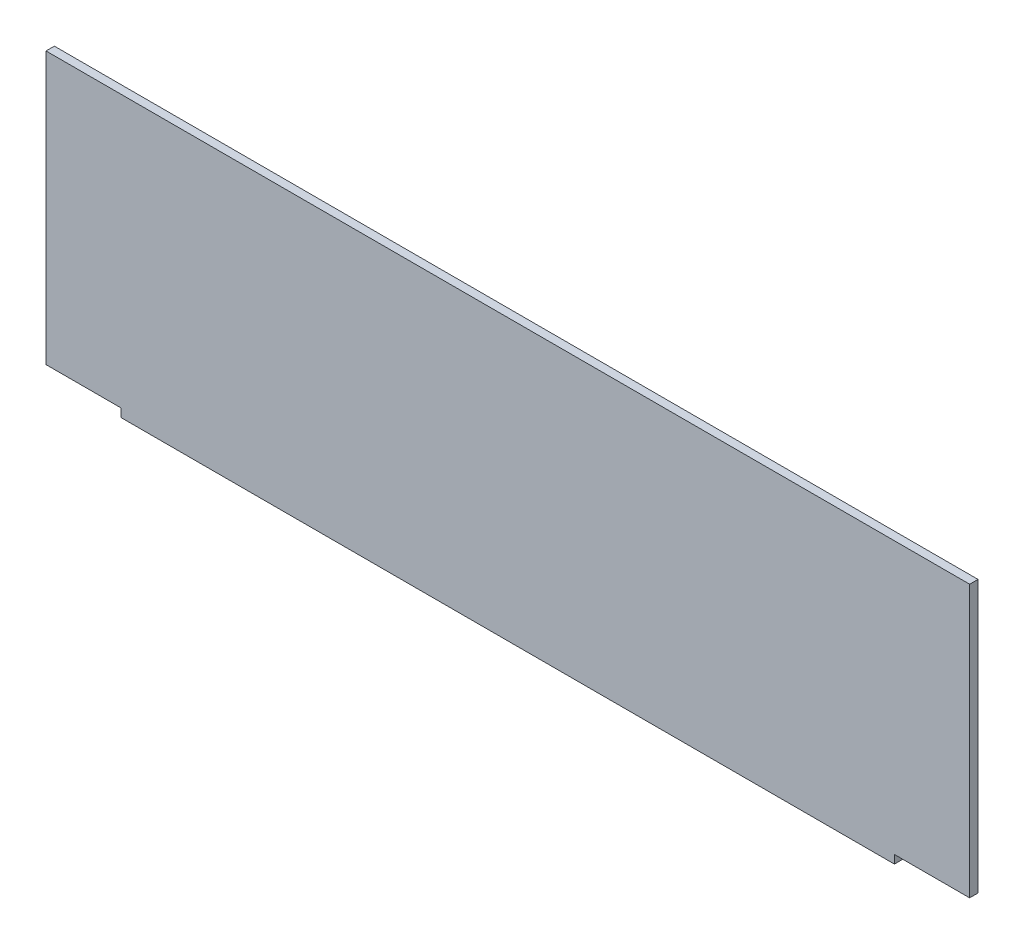
from build123d import *

# Parameters (mm, degrees)
EXTRUDE_1_DEPTH = 2


with BuildPart() as part:
    # 草图1 → 凸台-拉伸1 (new body)
    with BuildSketch(Plane.XY):
        Polygon((-92.5, -33.5), (92.5, -33.5), (92.5, -31.5), (110.5, -31.5), (110.5, 33.5), (-110.5, 33.5), (-110.5, -31.5), (-92.5, -31.5), align=None)
    extrude(amount=EXTRUDE_1_DEPTH)


solid = part.part
